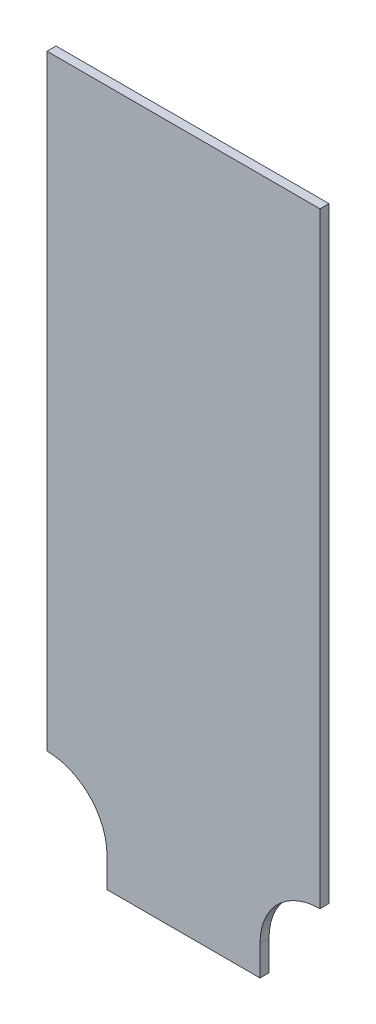
from build123d import *

# Parameters (mm, degrees)
EXTRUSION1_DEPTH = 3


with BuildPart() as part:
    # Esquisse1 → Extrusion1 (new body)
    with BuildSketch(Plane.XY):
        with BuildLine():
            Line((45.5, 232), (-45.5, 232))
            Line((-45.5, 232), (-45.5, 30))
            ThreePointArc((-45.5, 30), (-31.357864376, 24.142135624), (-25.5, 10))
            Line((-25.5, 10), (-25.5, 0))
            Line((-25.5, 0), (25.5, 0))
            Line((25.5, 0), (25.5, 10))
            ThreePointArc((25.5, 10), (31.357864376, 24.142135624), (45.5, 30))
            Line((45.5, 30), (45.5, 232))
        make_face()
    extrude(amount=EXTRUSION1_DEPTH)


solid = part.part
